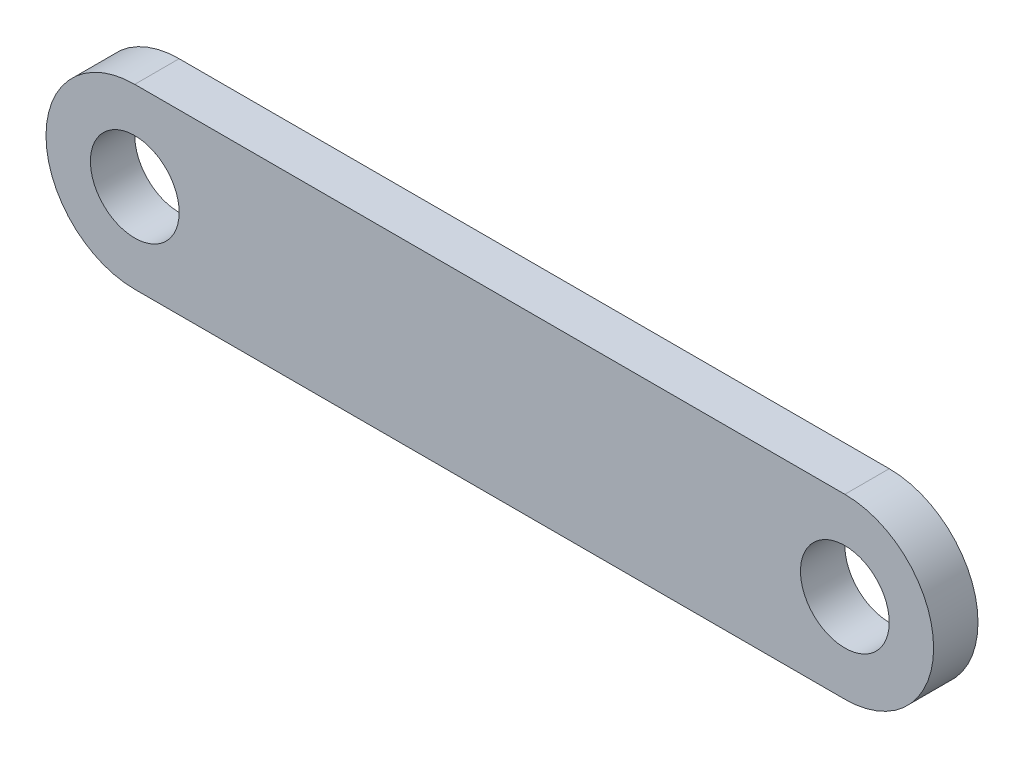
from build123d import *

# Parameters (mm, degrees)
SKETCH1_R           = 2
BOSS_EXTRUDE1_DEPTH = 1


with BuildPart() as part:
    # Sketch1 → Boss-Extrude1 (new body, symmetric)
    with BuildSketch(Plane.XY):
        with BuildLine():
            Line((0, 4), (32, 4))
            ThreePointArc((32, 4), (36, 0), (32, -4))
            Line((32, -4), (0, -4))
            ThreePointArc((0, -4), (-4, 0), (0, 4))
        make_face()
        Circle(SKETCH1_R, mode=Mode.SUBTRACT)
        with Locations((32, 0)):
            Circle(SKETCH1_R, mode=Mode.SUBTRACT)
    extrude(amount=BOSS_EXTRUDE1_DEPTH, both=True)


solid = part.part
